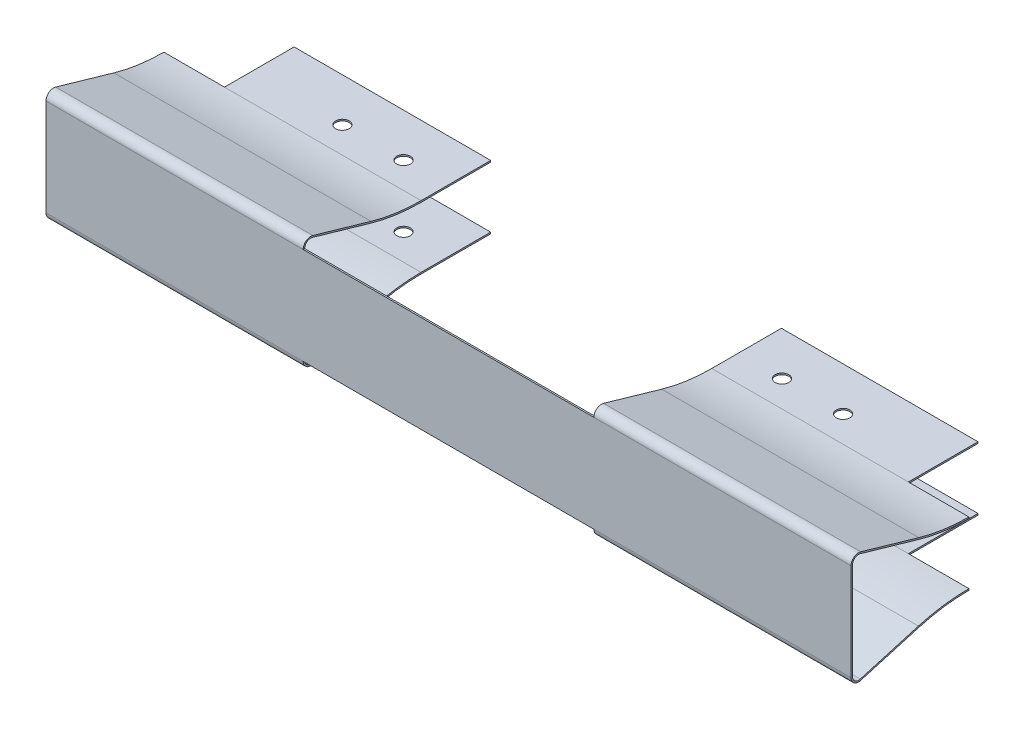
from build123d import *

# Parameters (mm, degrees)
EXTRUDE1_DEPTH          = 66.46
SKETCH2_W               = 48
SKETCH2_H               = 1.25
CUT_EXTRUDE1_DEPTH      = 26.22
SKETCH3_W               = 48
SKETCH3_H               = 30.72
CUT_EXTRUDE2_DEPTH      = 10.25
CUT_EXTRUDE2_DEPTH_BACK = 10.25
SKETCH4_R               = 1.125
SKETCH4_W               = 10
SKETCH4_H               = 11.5
CUT_EXTRUDE3_DEPTH      = 10.25
CUT_EXTRUDE3_DEPTH_BACK = 10.25


with BuildPart() as part:
    # Sketch1 → Extrude1 (new body, symmetric)
    with BuildSketch(Plane(origin=(0, 0, 0), x_dir=(0, 0, -1), z_dir=(1, 0, 0))):
        with BuildLine():
            Line((-24.97, 8), (-24.97, -8))
            ThreePointArc((-24.97, -8), (-24.570866698, -8.799349242), (-23.692081578, -8.96060468))
            Line((-23.692081578, -8.96060468), (-14.087552656, -6.181859607))
            ThreePointArc((-14.087552656, -6.181859607), (-9.960450582, -5.296934402), (-5.75, -5))
            Line((-5.75, -5), (5.75, -5))
            Line((5.75, -5), (5.75, -5.25))
            Line((5.75, -5.25), (-5.75, -5.25))
            ThreePointArc((-5.75, -5.25), (-9.925363494, -5.544459949), (-14.01807305, -6.422010777))
            Line((-14.01807305, -6.422010777), (-23.622601973, -9.20075585))
            ThreePointArc((-23.622601973, -9.20075585), (-24.721083373, -8.999186553), (-25.22, -8))
            Line((-25.22, -8), (-25.22, 8))
            ThreePointArc((-25.22, 8), (-24.721083373, 8.999186553), (-23.622601973, 9.20075585))
            Line((-23.622601973, 9.20075585), (-14.01807305, 6.422010777))
            ThreePointArc((-14.01807305, 6.422010777), (-9.925363494, 5.544459949), (-5.75, 5.25))
            Line((-5.75, 5.25), (5.75, 5.25))
            Line((5.75, 5.25), (5.75, 5))
            Line((5.75, 5), (-5.75, 5))
            ThreePointArc((-5.75, 5), (-9.960450582, 5.296934402), (-14.087552656, 6.181859607))
            Line((-14.087552656, 6.181859607), (-23.692081578, 8.96060468))
            ThreePointArc((-23.692081578, 8.96060468), (-24.570866698, 8.799349242), (-24.97, 8))
        make_face()
    extrude(amount=EXTRUDE1_DEPTH, both=True)

    # Sketch2 → Cut-Extrude1 (cut, through all)
    with BuildSketch(Plane.XY):
        with Locations((0, 8.625)):
            Rectangle(SKETCH2_W, SKETCH2_H)
        with Locations((0, -8.625)):
            Rectangle(SKETCH2_W, SKETCH2_H)
    extrude(amount=CUT_EXTRUDE1_DEPTH, mode=Mode.SUBTRACT)

    # Sketch3 → Cut-Extrude2 (cut, two sides)
    with BuildSketch(Plane(origin=(0, 0, 0), x_dir=(1, 0, 0), z_dir=(0, 1, 0))) as cut_extrude2_sk:
        with Locations((0, -9.61)):
            Rectangle(SKETCH3_W, SKETCH3_H)
    extrude(amount=CUT_EXTRUDE2_DEPTH, mode=Mode.SUBTRACT)
    extrude(cut_extrude2_sk.sketch, amount=-CUT_EXTRUDE2_DEPTH_BACK, mode=Mode.SUBTRACT)

    # Sketch4 → Cut-Extrude3 (cut, two sides)
    with BuildSketch(Plane(origin=(0, 0, 0), x_dir=(1, 0, 0), z_dir=(0, 1, 0))) as cut_extrude3_sk:
        with Locations(Location((-41.34, -1.4, 0), (0, 0, 270))):  # turned: the seam where the file's is
            Circle(SKETCH4_R)
        with Locations(Location((-31.24, -1.4, 0), (0, 0, 270))):  # turned: the seam where the file's is
            Circle(SKETCH4_R)
        with Locations(Location((31.24, -1.4, 0), (0, 0, 270))):  # turned: the seam where the file's is
            Circle(SKETCH4_R)
        with Locations(Location((41.34, -1.4, 0), (0, 0, 270))):  # turned: the seam where the file's is
            Circle(SKETCH4_R)
        with Locations((-61.46, 0)):
            Rectangle(SKETCH4_W, SKETCH4_H)
        with Locations((61.46, 0)):
            Rectangle(SKETCH4_W, SKETCH4_H)
    extrude(amount=CUT_EXTRUDE3_DEPTH, mode=Mode.SUBTRACT)
    extrude(cut_extrude3_sk.sketch, amount=-CUT_EXTRUDE3_DEPTH_BACK, mode=Mode.SUBTRACT)


solid = part.part
